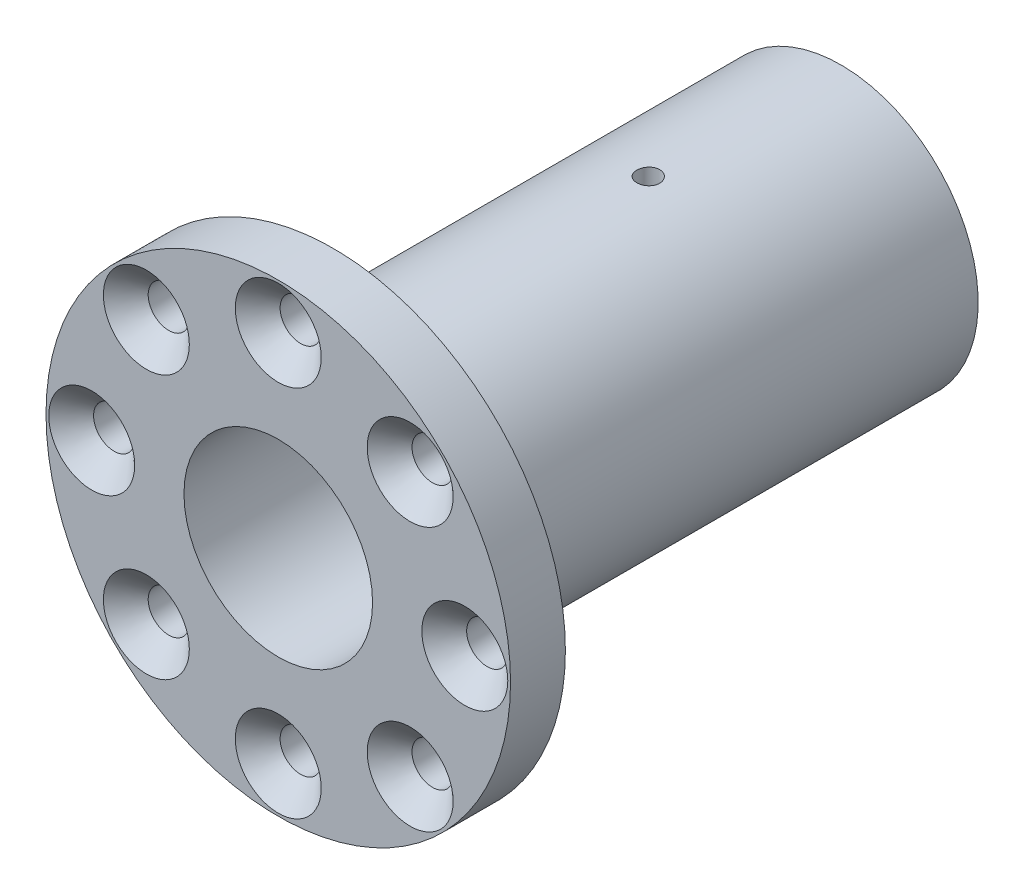
from build123d import *

# Parameters (mm, degrees)
SKETCH1_W                                         = 25.4
SKETCH1_H                                         = 6
SKETCH2_R                                         = 15
BOSS_EXTRUDE1_DEPTH                               = 55.54
CUT_EXTRUDE1_DEPTH                                = 62.54
SKETCH4_W                                         = 7.0104
SKETCH4_H                                         = 61.54
F_2_CLEARANCE_HOLE1_D                             = 2.5
F_2_CLEARANCE_HOLE1_DEPTH                         = 12
SKETCH7_W                                         = 1.25
SKETCH7_H                                         = 16.341500105
CSK_FOR_8_FLAT_HEAD_MACHINE_SCREW_100_D           = 4.5
CSK_FOR_8_FLAT_HEAD_MACHINE_SCREW_100_DEPTH       = 61.54
CSK_FOR_8_FLAT_HEAD_MACHINE_SCREW_100_CSINK_D     = 9.4
CSK_FOR_8_FLAT_HEAD_MACHINE_SCREW_100_CSINK_ANGLE = 90
SKETCH11_R                                        = 10.3124
CUT_EXTRUDE2_DEPTH                                = 38.1


with BuildPart() as part:
    # Sketch1 → Revolve1 (revolve)
    with BuildSketch(Plane.XZ):
        with Locations((12.7, 58.54)):
            Rectangle(SKETCH1_W, SKETCH1_H)
    revolve(axis=Axis((0, 0, 61.54), (0, 0, -1)))

    # Sketch2 → Boss-Extrude1 (add)
    with BuildSketch(Plane(origin=(0, 0, 55.54), x_dir=(-1, 0, 0), z_dir=(0, 0, -1))):
        Circle(SKETCH2_R)
    extrude(amount=BOSS_EXTRUDE1_DEPTH)

    # Sketch3 → Cut-Extrude1 (cut, through all)
    with BuildSketch(Plane(origin=(0, 0, 0), x_dir=(-1, 0, 0), z_dir=(0, 0, -1))):
        with BuildLine():
            Line((2.5, 9.058499895), (-2.5, 9.058499895))
            Line((-2.5, 9.058499895), (-2.5, 6.538348415))
            ThreePointArc((-2.5, 6.538348415), (0, 7), (2.5, 6.538348415))
            Line((2.5, 6.538348415), (2.5, 9.058499895))
        make_face()
    extrude(amount=-CUT_EXTRUDE1_DEPTH, mode=Mode.SUBTRACT)

    # Sketch4 → Cut-Revolve1 (revolve, cut)
    with BuildSketch(Plane.XZ):
        with Locations((3.5052, 30.77)):
            Rectangle(SKETCH4_W, SKETCH4_H)
    revolve(axis=Axis((0, 0, 61.54), (0, 0, -1)), mode=Mode.SUBTRACT)

    # #2 Clearance Hole1
    with Locations(Plane(origin=(0, 0, 0), x_dir=(-1, 0, 0), z_dir=(0, 0, -1))):
        with Locations((-11.5, 0), (-5.75, -9.959292144), (5.75, -9.959292144), (11.5, 0), (5.75, 9.959292144), (-5.75, 9.959292144)):
            Hole(F_2_CLEARANCE_HOLE1_D / 2, depth=F_2_CLEARANCE_HOLE1_DEPTH)

    # Sketch7 → #2 Clearance Hole2 (revolve, cut)
    with BuildSketch(Plane(origin=(0, 9.058499895, 21.082), x_dir=(0, 0, -1), z_dir=(1, 0, 0))):
        with Locations((0.625, 8.170750053)):
            Rectangle(SKETCH7_W, SKETCH7_H)
    revolve(axis=Axis((0, 2.708499895, 21.082), (0, 1, 0)), mode=Mode.SUBTRACT)

    # CSK for #8 Flat Head Machine Screw (100)1
    with Locations(Plane.XY.offset(61.54)):
        with Locations((0, 20.4), (14.424978336, 14.424978336), (20.4, 0), (14.424978336, -14.424978336), (0, -20.4), (-14.424978336, -14.424978336), (-20.4, 0), (-14.424978336, 14.424978336)):
            CounterSinkHole(CSK_FOR_8_FLAT_HEAD_MACHINE_SCREW_100_D / 2, CSK_FOR_8_FLAT_HEAD_MACHINE_SCREW_100_CSINK_D / 2, depth=CSK_FOR_8_FLAT_HEAD_MACHINE_SCREW_100_DEPTH, counter_sink_angle=CSK_FOR_8_FLAT_HEAD_MACHINE_SCREW_100_CSINK_ANGLE)

    # Sketch11 → Cut-Extrude2 (cut)
    with BuildSketch(Plane.XY.offset(61.54)):
        Circle(SKETCH11_R)
    extrude(amount=-CUT_EXTRUDE2_DEPTH, mode=Mode.SUBTRACT)


solid = part.part
